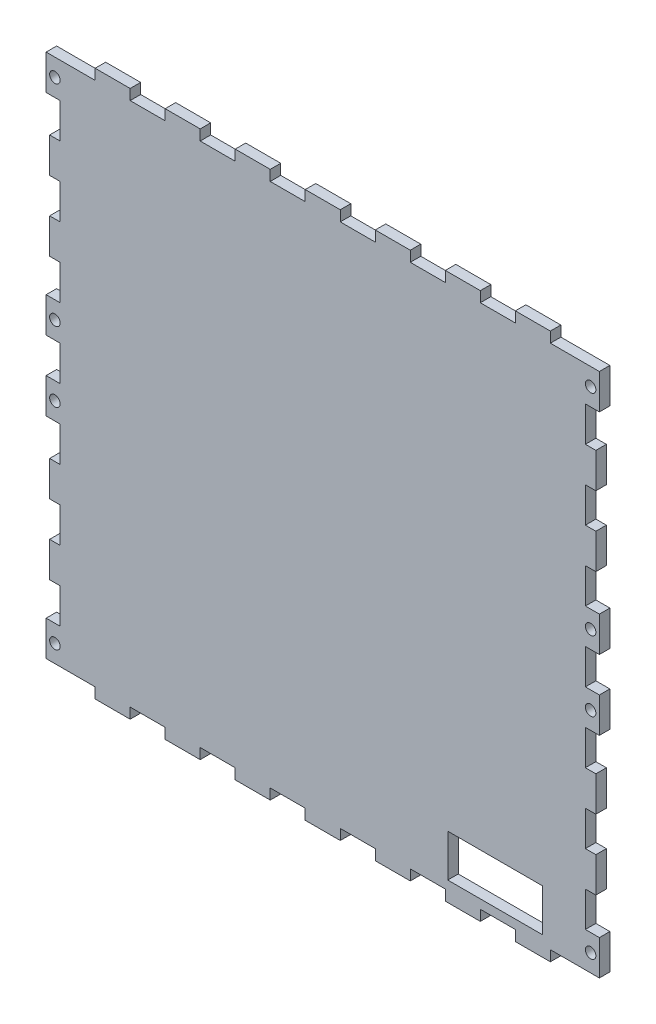
from build123d import *

# Parameters (mm, degrees)
SKETCH2_R           = 1.5
BOSS_EXTRUDE2_DEPTH = 3
SKETCH3_W           = 27
SKETCH3_H           = 12.089495281
CUT_EXTRUDE1_DEPTH  = 10


with BuildPart() as part:
    # Sketch2 → Boss-Extrude2 (new body)
    with BuildSketch(Plane.XY):
        Polygon((143.230702788, -0.118374558), (153.230702788, -0.118374558), (157.230702788, -0.118374558), (157.230702788, 9.881625442), (153.230702788, 9.881625442), (153.230702788, 19.881625442), (156.230702788, 19.881625442), (156.230702788, 29.881625442), (153.230702788, 29.881625442), (153.230702788, 39.881625442), (156.230702788, 39.881625442), (156.230702788, 49.881625442), (153.230702788, 49.881625442), (153.230702788, 59.881625442), (157.230702788, 59.881625442), (157.230702788, 69.881625442), (153.230702788, 69.881625442), (153.230702788, 79.881625442), (157.230702788, 79.881625442), (157.230702788, 89.881625442), (153.230702788, 89.881625442), (153.230702788, 99.881625442), (156.230702788, 99.881625442), (156.230702788, 109.881625442), (153.230702788, 109.881625442), (153.230702788, 119.881625442), (156.230702788, 119.881625442), (156.230702788, 129.881625442), (153.230702788, 129.881625442), (153.230702788, 139.881625442), (157.230702788, 139.881625442), (157.230702788, 149.88750096), (153.230702788, 149.88750096), (143.230702788, 149.88750096), (143.230702788, 152.88750096), (133.230702788, 152.88750096), (133.230702788, 149.88750096), (123.230702788, 149.88750096), (123.230702788, 152.88750096), (113.230702788, 152.88750096), (113.230702788, 149.88750096), (103.230702788, 149.88750096), (103.230702788, 152.88750096), (93.230702788, 152.88750096), (93.230702788, 149.88750096), (83.230702788, 149.88750096), (83.230702788, 152.88750096), (73.230702788, 152.88750096), (73.230702788, 149.88750096), (63.230702788, 149.88750096), (63.230702788, 152.88750096), (53.230702788, 152.88750096), (53.230702788, 149.88750096), (43.230702788, 149.88750096), (43.230702788, 152.88750096), (33.230702788, 152.88750096), (33.230702788, 149.88750096), (23.230702788, 149.88750096), (23.230702788, 152.88750096), (13.230702788, 152.88750096), (13.230702788, 149.88750096), (3.230702788, 149.88750096), (-0.769297212, 149.88750096), (-0.769297212, 139.881625442), (3.230702788, 139.881625442), (3.230702788, 129.881625442), (0.230702788, 129.881625442), (0.230702788, 119.881625442), (3.230702788, 119.881625442), (3.230702788, 109.881625442), (0.230702788, 109.881625442), (0.230702788, 99.881625442), (3.230702788, 99.881625442), (3.230702788, 89.881625442), (-0.769297212, 89.881625442), (-0.769297212, 79.881625442), (3.230702788, 79.881625442), (3.230702788, 69.881625442), (-0.769297212, 69.881625442), (-0.769297212, 59.881625442), (3.230702788, 59.881625442), (3.230702788, 49.881625442), (0.230702788, 49.881625442), (0.230702788, 39.881625442), (3.230702788, 39.881625442), (3.230702788, 29.881625442), (0.230702788, 29.881625442), (0.230702788, 19.881625442), (3.230702788, 19.881625442), (3.230702788, 9.881625442), (-0.769297212, 9.881625442), (-0.769297212, -0.118374558), (3.230702788, -0.118374558), (13.230702788, -0.118374558), (13.230702788, -3.118374558), (23.230702788, -3.118374558), (23.230702788, -0.118374558), (33.230702788, -0.118374558), (33.230702788, -3.118374558), (43.230702788, -3.118374558), (43.230702788, -0.118374558), (53.230702788, -0.118374558), (53.230702788, -3.118374558), (63.230702788, -3.118374558), (63.230702788, -0.118374558), (73.230702788, -0.118374558), (73.230702788, -3.118374558), (83.230702788, -3.118374558), (83.230702788, -0.118374558), (93.230702788, -0.118374558), (93.230702788, -3.118374558), (103.230702788, -3.118374558), (103.230702788, -0.118374558), (113.230702788, -0.118374558), (113.230702788, -3.118374558), (123.230702788, -3.118374558), (123.230702788, -0.118374558), (133.230702788, -0.118374558), (133.230702788, -3.118374558), (143.230702788, -3.118374558), align=None)
        with Locations((1.730702788, 4.884563201)):
            Circle(SKETCH2_R, mode=Mode.SUBTRACT)
        with Locations((1.730702788, 64.884563201)):
            Circle(SKETCH2_R, mode=Mode.SUBTRACT)
        with Locations((154.730702788, 4.884563201)):
            Circle(SKETCH2_R, mode=Mode.SUBTRACT)
        with Locations((154.730702788, 64.884563201)):
            Circle(SKETCH2_R, mode=Mode.SUBTRACT)
        with Locations((1.730702788, 84.884563201)):
            Circle(SKETCH2_R, mode=Mode.SUBTRACT)
        with Locations((1.730702788, 144.884563201)):
            Circle(SKETCH2_R, mode=Mode.SUBTRACT)
        with Locations((154.730702788, 84.884563201)):
            Circle(SKETCH2_R, mode=Mode.SUBTRACT)
        with Locations((154.730702788, 144.884563201)):
            Circle(SKETCH2_R, mode=Mode.SUBTRACT)
    extrude(amount=BOSS_EXTRUDE2_DEPTH)

    # Sketch3 → Cut-Extrude1 (cut)
    with BuildSketch(Plane(origin=(0, 0, 0), x_dir=(-1, 0, 0), z_dir=(0, 0, -1))):
        with Locations((-127.430702788, 8.503599334)):
            Rectangle(SKETCH3_W, SKETCH3_H)
    extrude(amount=-CUT_EXTRUDE1_DEPTH, mode=Mode.SUBTRACT)


solid = part.part
